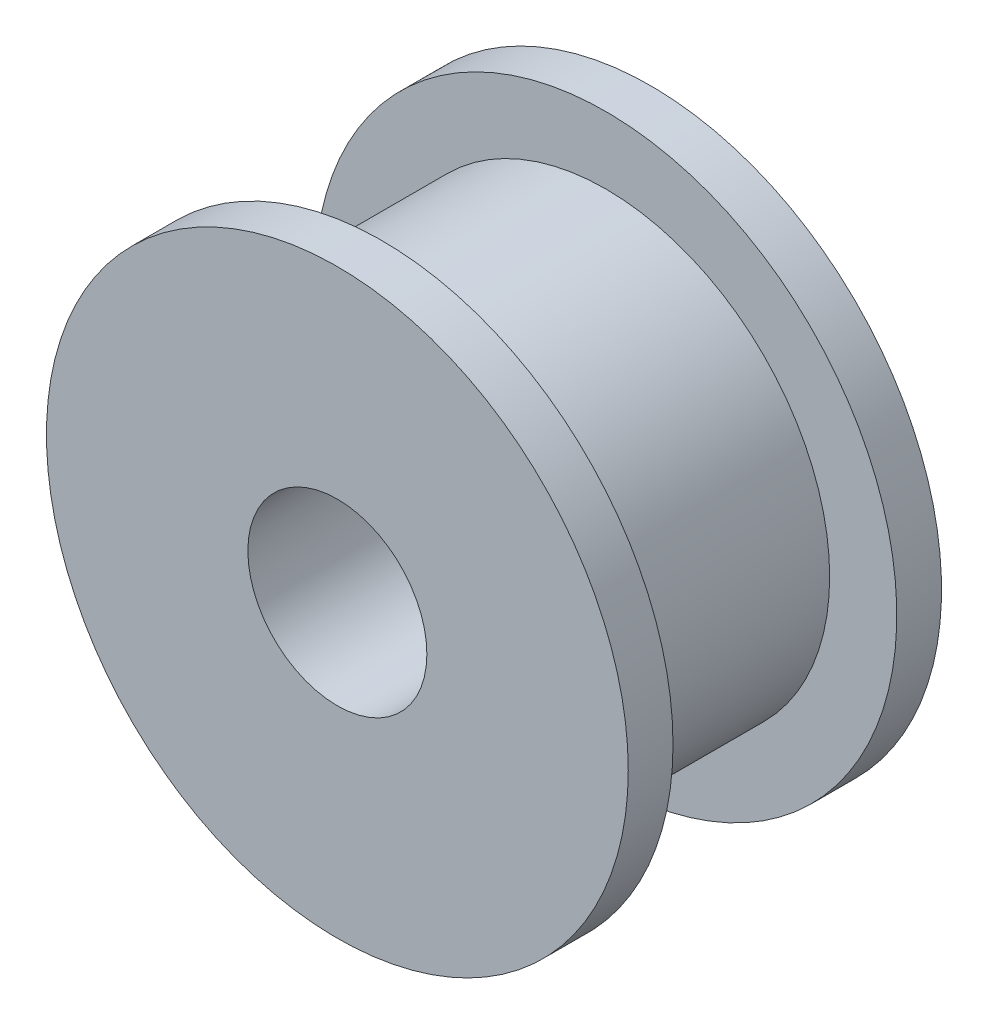
from build123d import *

# Parameters (mm, degrees)
SKETCH_1_R      = 5
SKETCH_1_R_2    = 2
EXTRUDE_1_DEPTH = 2.5
SKETCH_2_R      = 6.5
SKETCH_2_R_2    = 2
EXTRUDE_2_DEPTH = 1
SKETCH_3_R      = 6.5
SKETCH_3_R_2    = 2
EXTRUDE_3_DEPTH = 1


with BuildPart() as part:
    # 스케치1 → 보스-돌출1 (new body, symmetric)
    with BuildSketch(Plane.XY):
        Circle(SKETCH_1_R)
        Circle(SKETCH_1_R_2, mode=Mode.SUBTRACT)
    extrude(amount=EXTRUDE_1_DEPTH, both=True)

    # 스케치2 → 보스-돌출2 (add)
    with BuildSketch(Plane(origin=(0, 0, -2.5), x_dir=(-1, 0, 0), z_dir=(0, 0, -1))):
        Circle(SKETCH_2_R)
        Circle(SKETCH_2_R_2, mode=Mode.SUBTRACT)
    extrude(amount=EXTRUDE_2_DEPTH)

    # 스케치3 → 보스-돌출3 (add)
    with BuildSketch(Plane.XY.offset(2.5)):
        Circle(SKETCH_3_R)
        Circle(SKETCH_3_R_2, mode=Mode.SUBTRACT)
    extrude(amount=EXTRUDE_3_DEPTH)


solid = part.part
